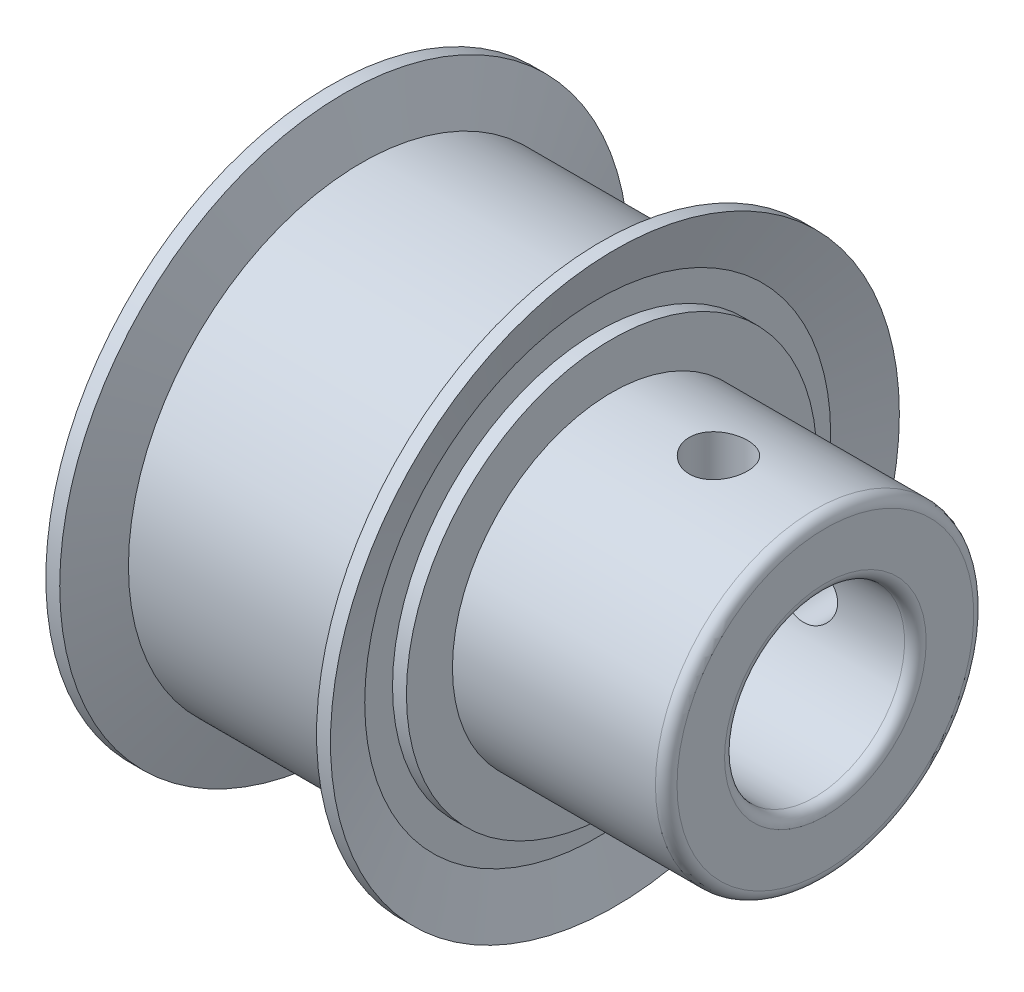
from build123d import *

# Parameters (mm, degrees)
SKETCH3_R         = 1.0287
SCREW_HOLE_DEPTH  = 11.033
CIRPATTERN1_COUNT = 2
CIRPATTERN1_ANGLE = 90
FILLET1_R         = 0.381


with BuildPart() as part:
    # Sketch2 → PULLEY (revolve)
    with BuildSketch(Plane.XY):
        Polygon((-8.6725125, 3.175), (8.6725125, 3.175), (8.6725125, 5.6134), (1.1318875, 5.6134), (1.1318875, 7.23646), (0.1514475, 7.23646), (0.1514475, 8.2169), (-7.6920725, 8.2169), (-7.6920725, 7.23646), (-8.6725125, 7.23646), align=None)
    revolve(axis=Axis((-8.6725125, 0, 0), (1, 0, 0)))

    # Sketch4 → Flange (revolve)
    with BuildSketch(Plane.XY):
        Polygon((-8.1822925, 7.23646), (-8.1822925, 8.2169), (-8.7899875, 10.033), (-8.2997675, 10.033), (-7.6920725, 8.2169), (-7.6920725, 7.23646), align=None)
        Polygon((0.1514475, 7.23646), (0.6416675, 7.23646), (0.6416675, 8.2169), (1.2493625, 10.033), (0.7591425, 10.033), (0.1514475, 8.2169), align=None)
    revolve(axis=Axis((0, 0, 0), (-1, 0, 0)))

    # Sketch3 → SCREW HOLE (cut, through all)
    with BuildSketch(Plane(origin=(0, 0, 0), x_dir=(1, 0, 0), z_dir=(0, 1, 0))):
        with Locations((4.9022, 0)):
            Circle(SKETCH3_R)
    screw_hole = extrude(amount=SCREW_HOLE_DEPTH, mode=Mode.SUBTRACT)

    # CirPattern1: SCREW HOLE ×2 about axis
    cirpattern1_axis = Axis((-8.6725125, 0, 0), (-1, 0, 0))
    for i in range(1, CIRPATTERN1_COUNT):
        add(screw_hole.rotate(cirpattern1_axis, i * CIRPATTERN1_ANGLE / (CIRPATTERN1_COUNT - 1)), mode=Mode.SUBTRACT)

    # Fillet1
    fillet1_edges = [part.edges().sort_by_distance(p)[0] for p in [
        (-8.6725125, -3.175, 0),
        (8.6725125, -3.175, 0),
        (8.6725125, -5.6134, 0),
    ]]
    fillet(fillet1_edges, radius=FILLET1_R)


solid = part.part
